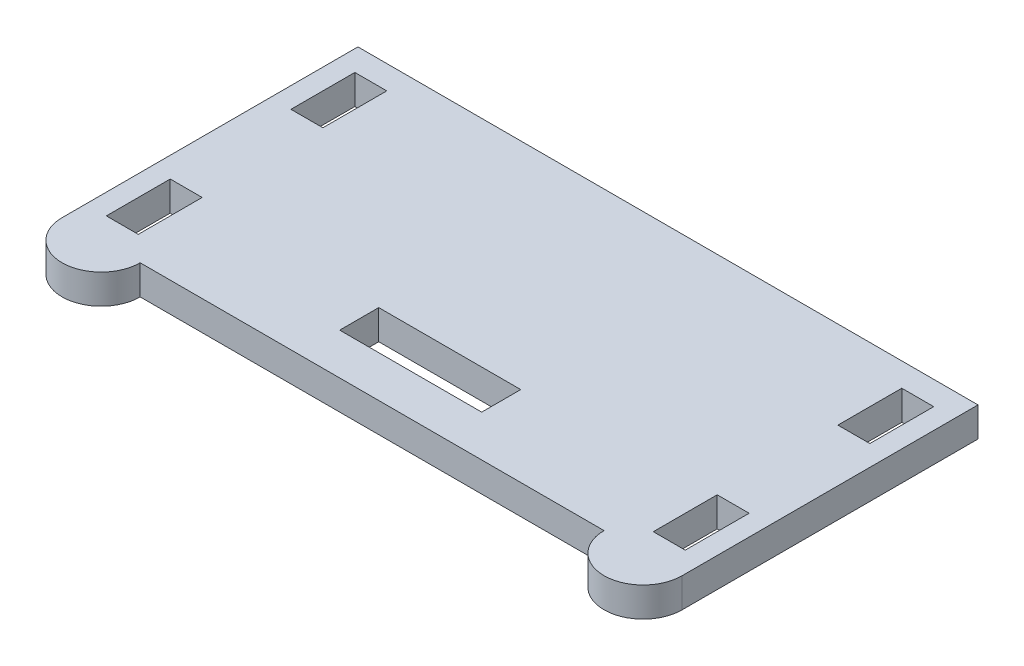
from build123d import *

# Parameters (mm, degrees)
SKETCH1_W           = 3.429
SKETCH1_H           = 6.858
SKETCH1_W_2         = 15.24
SKETCH1_H_2         = 4.191
BOSS_EXTRUDE1_DEPTH = 3.175


with BuildPart() as part:
    # Sketch1 → Boss-Extrude1 (new body)
    with BuildSketch(Plane(origin=(0, 0, 0), x_dir=(1, 0, 0), z_dir=(0, 1, 0))):
        with BuildLine():
            Line((-24.892, -15.875), (24.892, -15.875))
            ThreePointArc((24.892, -15.875), (29.083, -20.066), (33.274, -15.875))
            Line((33.274, -15.875), (33.274, 15.875))
            Line((33.274, 15.875), (-33.274, 15.875))
            Line((-33.274, 15.875), (-33.274, -15.875))
            ThreePointArc((-33.274, -15.875), (-29.083, -20.066), (-24.892, -15.875))
        make_face()
        with Locations((29.3497, 9.906)):
            Rectangle(SKETCH1_W, SKETCH1_H, mode=Mode.SUBTRACT)
        with Locations((29.3497, -9.906)):
            Rectangle(SKETCH1_W, SKETCH1_H, mode=Mode.SUBTRACT)
        with Locations((-29.3497, -9.906)):
            Rectangle(SKETCH1_W, SKETCH1_H, mode=Mode.SUBTRACT)
        with Locations((-29.3497, 9.906)):
            Rectangle(SKETCH1_W, SKETCH1_H, mode=Mode.SUBTRACT)
        with Locations((-0.3048, -9.3345)):
            Rectangle(SKETCH1_W_2, SKETCH1_H_2, mode=Mode.SUBTRACT)
    extrude(amount=BOSS_EXTRUDE1_DEPTH)


solid = part.part
